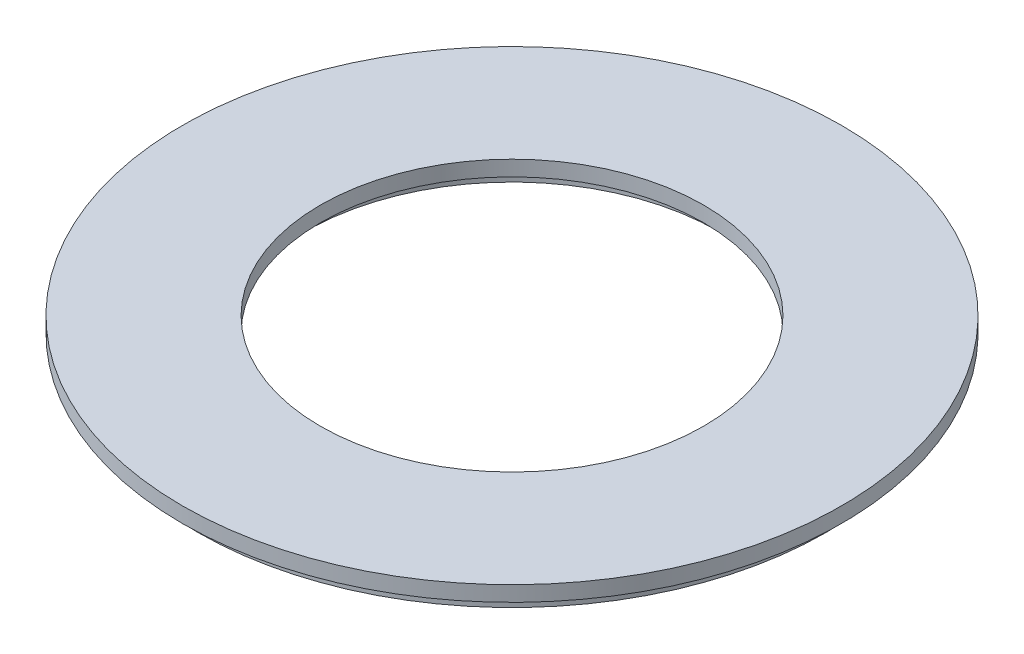
from build123d import *

# Parameters (mm, degrees)
SKETCH1_R           = 21.5
SKETCH1_R_2         = 12.5
BOSS_EXTRUDE1_DEPTH = 1
SKETCH2_R           = 20.5
SKETCH2_R_2         = 13.5
BOSS_EXTRUDE2_DEPTH = 1


with BuildPart() as part:
    # Sketch1 → Boss-Extrude1 (new body)
    with BuildSketch(Plane(origin=(0, 0, 0), x_dir=(1, 0, 0), z_dir=(0, 1, 0))):
        Circle(SKETCH1_R)
        Circle(SKETCH1_R_2, mode=Mode.SUBTRACT)
    extrude(amount=BOSS_EXTRUDE1_DEPTH)

    # Sketch2 → Boss-Extrude2 (add)
    with BuildSketch(Plane.XZ):
        Circle(SKETCH2_R)
        Circle(SKETCH2_R_2, mode=Mode.SUBTRACT)
    extrude(amount=BOSS_EXTRUDE2_DEPTH)


solid = part.part
